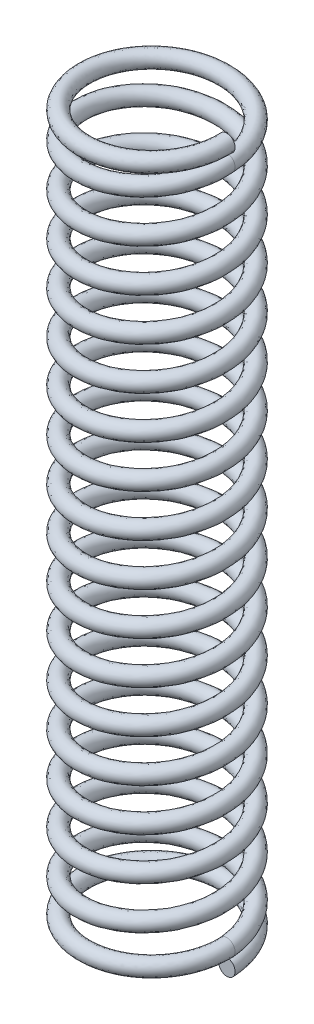
from build123d import *

# Parameters (mm, degrees)
SWEEP1_PITCH       = 1.5113
SWEEP1_HEIGHT      = 24.1808
SWEEP1_RADIUS      = 2.778125
SWEEP1_START_ANGLE = 90
SKETCH1_R          = 0.2921
SWEEP2_PITCH       = 0.6096
SWEEP2_HEIGHT      = 0.6096
SWEEP2_RADIUS      = 2.778125
SWEEP2_START_ANGLE = 90
SKETCH5_R          = 0.2921
SWEEP3_PITCH       = 0.6096
SWEEP3_HEIGHT      = 0.6096
SWEEP3_RADIUS      = 2.778125
SWEEP3_START_ANGLE = 90
SKETCH7_R          = 0.2921


with BuildPart() as part:
    # Sweep1: sweep along a helix
    with BuildLine() as sweep1_path:
        add(Helix(SWEEP1_PITCH, SWEEP1_HEIGHT, SWEEP1_RADIUS, center=(0, 0.6096, 0), direction=(0, 1, 0), mode=Mode.PRIVATE).rotate(Axis((0, 0.6096, 0), (0, 1, 0)), SWEEP1_START_ANGLE))
    # Sketch1 → Sweep1 (sweep)
    with BuildSketch(Plane.XY):
        with Locations((2.486025, 0.6096)):
            Circle(SKETCH1_R)
    sweep(path=sweep1_path.line, is_frenet=True)

    # Sweep2: sweep along a helix
    with BuildLine() as sweep2_path:
        add(Helix(SWEEP2_PITCH, SWEEP2_HEIGHT, SWEEP2_RADIUS, center=(0, 0.6096, 0), direction=(0, -1, 0), mode=Mode.PRIVATE).rotate(Axis((0, 0.6096, 0), (0, -1, 0)), SWEEP2_START_ANGLE))
    # Sketch5 → Sweep2 (sweep)
    with BuildSketch(Plane.XY):
        with Locations((2.486025, 0)):
            Circle(SKETCH5_R)
    sweep(path=sweep2_path.line, is_frenet=True)

    # Sweep3: sweep along a helix
    with BuildLine() as sweep3_path:
        add(Helix(SWEEP3_PITCH, SWEEP3_HEIGHT, SWEEP3_RADIUS, center=(0, 24.7904, 0), direction=(0, 1, 0), mode=Mode.PRIVATE).rotate(Axis((0, 24.7904, 0), (0, 1, 0)), SWEEP3_START_ANGLE))
    # Sketch7 → Sweep3 (sweep)
    with BuildSketch(Plane.XY):
        with Locations((2.486025, 24.7904)):
            Circle(SKETCH7_R)
    sweep(path=sweep3_path.line, is_frenet=True)


solid = part.part
